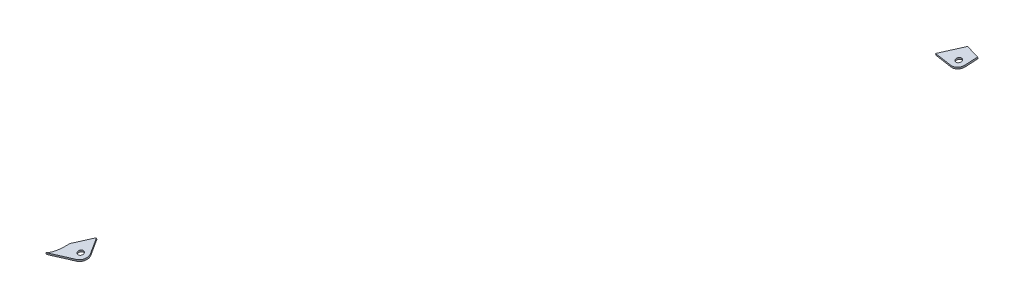
from build123d import *

# Parameters (mm, degrees)
SZKIC1_R                      = 3
DODANIE_WYCI_GNI_CIE1_DEPTH   = 2
DODANIE_WYCI_GNI_CIE1_2_DEPTH = 2


with BuildPart() as part:
    # Szkic1 → Dodanie-wyciągnięcie1 (new body)
    with BuildSketch(Plane(origin=(0, 365.945689179, 71.13263619), x_dir=(-1, 0, 0), z_dir=(0, -0.981627183, -0.190808995))):
        with BuildLine():
            Line((-1362.923797729, -419.854107682), (-1364.538000279, -407.319872061))
            add(Edge.make_bspline(
                [(-1349.701807109, -403.530365456), (-1355.02305477, -404.99505528), (-1359.97623472, -406.256350894), (-1364.538000279, -407.319872061)],
                knots=[0.941558542, 0.941558542, 0.941558542, 0.941558542, 0.993310921, 0.993310921, 0.993310921, 0.993310921], degree=3, weights=[0.880926245, 0.911422555, 0.94603838, 0.984773721]))
            add(Edge.make_bspline(
                [(-1334.808410224, -424.29937802), (-1339.775715665, -417.372446761), (-1344.740184818, -410.449437658), (-1349.701807109, -403.530365456)],
                knots=[0.963874291, 0.963874291, 0.963874291, 0.963874291, 1, 1, 1, 1], degree=3, weights=[0.999942295, 0.999960809, 0.999980044, 1]))
            Line((-1334.808410224, -424.29937802), (-1353.967495394, -426.766751785))
            ThreePointArc((-1353.967495394, -426.766751785), (-1359.877302031, -425.165340681), (-1362.923797729, -419.854107682))
        make_face()
        with Locations((-1354.98932451, -418.832278566)):
            Circle(SZKIC1_R, mode=Mode.SUBTRACT)
    extrude(amount=-DODANIE_WYCI_GNI_CIE1_DEPTH)


with BuildPart() as body_2:
    # Szkic1 → Dodanie-wyci_gni_cie1 2 (new body)
    with BuildSketch(Plane(origin=(0, 365.945689179, 71.13263619), x_dir=(-1, 0, 0), z_dir=(0, -0.981627183, -0.190808995))):
        with BuildLine():
            Line((-952.848375327, -984.825791702), (-944.055127392, -969.140346063))
            add(Edge.make_bspline(
                [(-931.575131618, -986.539510746), (-935.73656816, -980.737805888), (-939.896568771, -974.938081512), (-944.055127392, -969.140346063)],
                knots=[0, 0, 0, 0, 0.029475702, 0.029475702, 0.029475702, 0.029475702], degree=3, weights=[1, 0.999983717, 0.999967915, 0.999952592]))
            add(Edge.make_bspline(
                [(-923.569906868, -1005.011346587), (-923.978106771, -1004.744128104), (-924.361430622, -1004.441990869), (-924.933250587, -1003.922432382), (-925.135186128, -1003.723447225), (-925.5212225, -1003.315189544), (-925.706214443, -1003.105145705), (-926.596451968, -1002.029337731), (-927.201304915, -1001.08702776), (-928.265984349, -999.106110043), (-928.714956529, -998.086344366), (-929.501728034, -996.007731579), (-929.838676077, -994.948585213), (-930.429066466, -992.800937093), (-930.682852112, -991.708936691), (-931.17392663, -989.258796767), (-931.393872963, -987.900039795), (-931.575131618, -986.539510746)],
                knots=[0.533256834, 0.533256834, 0.533256834, 0.533256834, 0.546875, 0.546875, 0.5546875, 0.5546875, 0.5625, 0.5625, 0.59375, 0.59375, 0.625, 0.625, 0.65625, 0.65625, 0.6875, 0.6875, 0.726253318, 0.726253318, 0.726253318, 0.726253318], degree=3))
            Line((-923.569906868, -1005.011346587), (-948.510924792, -996.28936399))
            ThreePointArc((-948.510924792, -996.28936399), (-953.352425834, -991.568871046), (-952.848375327, -984.825791702))
        make_face()
        with Locations((-945.87011042, -988.737801274)):
            Circle(SZKIC1_R, mode=Mode.SUBTRACT)
    extrude(amount=-DODANIE_WYCI_GNI_CIE1_2_DEPTH)


solid = Compound([part.part, body_2.part])
